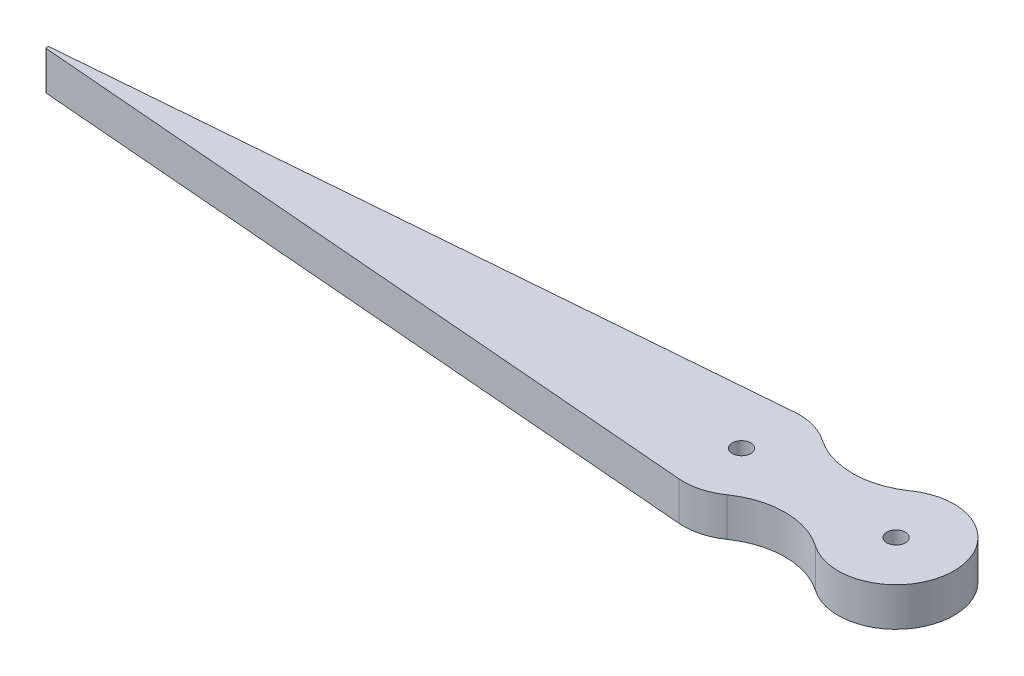
from build123d import *

# Parameters (mm, degrees)
SKETCH1_R           = 1.524
BOSS_EXTRUDE1_DEPTH = 6.35
FILLET1_R           = 0.254


with BuildPart() as part:
    # Sketch1 → Boss-Extrude1 (new body)
    with BuildSketch(Plane(origin=(0, 0, 0), x_dir=(1, 0, 0), z_dir=(0, 1, 0))):
        with BuildLine():
            Line((-0.774889862, 9.493427764), (-117.081961553, 0))
            Line((-117.081961553, 0), (-0.774889862, -9.493427764))
            ThreePointArc((-0.774889862, -9.493427764), (2.47998519, -9.19648294), (5.442857143, -7.816708458))
            ThreePointArc((5.442857143, -7.816708458), (12.7, -5.538986403), (19.957142857, -7.816708458))
            ThreePointArc((19.957142857, -7.816708458), (34.925, 0), (19.957142857, 7.816708458))
            ThreePointArc((19.957142857, 7.816708458), (12.7, 5.538986403), (5.442857143, 7.816708458))
            ThreePointArc((5.442857143, 7.816708458), (2.47998519, 9.19648294), (-0.774889862, 9.493427764))
        make_face()
        Circle(SKETCH1_R, mode=Mode.SUBTRACT)
        with Locations((25.4, 0)):
            Circle(SKETCH1_R, mode=Mode.SUBTRACT)
    extrude(amount=BOSS_EXTRUDE1_DEPTH)

    # Fillet1
    fillet1_edges = [part.edges().sort_by_distance(p)[0] for p in [
        (-117.081961553, 3.175, 0),
    ]]
    fillet(fillet1_edges, radius=FILLET1_R)


solid = part.part
